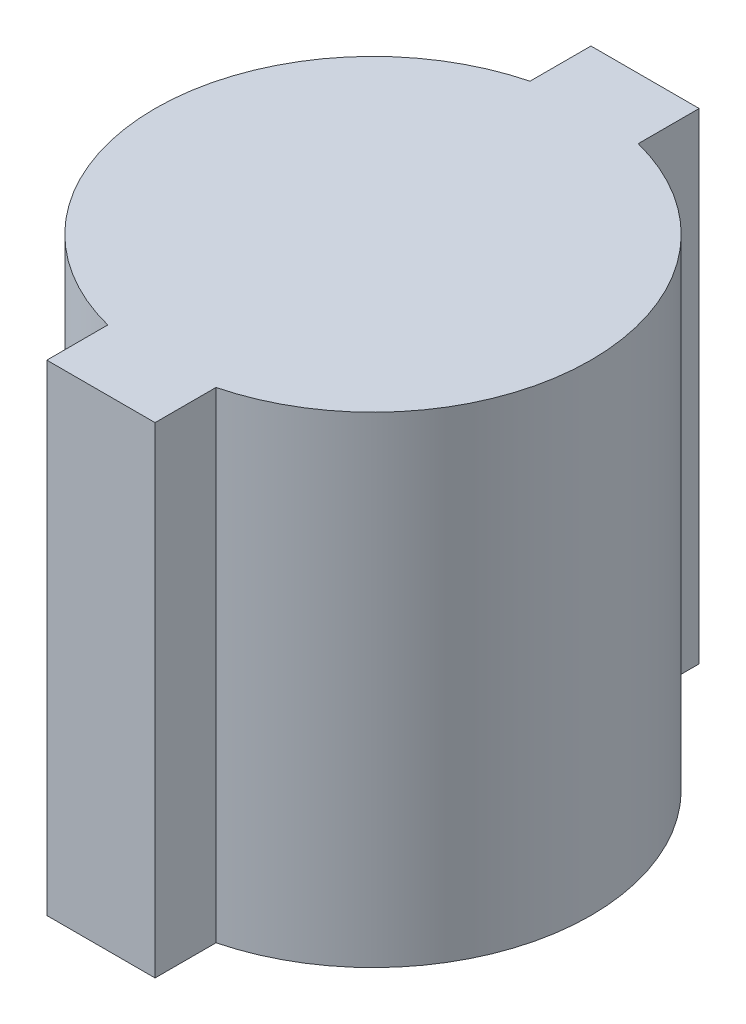
from build123d import *

# Parameters (mm, degrees)
BOSS_EXTRUDE1_DEPTH = 20.32


with BuildPart() as part:
    # Sketch1 → Boss-Extrude1 (new body)
    with BuildSketch(Plane(origin=(0, 0, 0), x_dir=(1, 0, 0), z_dir=(0, 1, 0))):
        with BuildLine():
            Line((-2.286, 11.4935), (-2.286, 8.919207378))
            ThreePointArc((-2.286, 8.919207378), (0, 9.2075), (2.286, 8.919207378))
            Line((2.286, 8.919207378), (2.286, 11.4935))
            Line((2.286, 11.4935), (-2.286, 11.4935))
        make_face()
        with BuildLine():
            Line((-2.286, 8.919207378), (-2.286, 6.9215))
            Line((-2.286, 6.9215), (2.286, 6.9215))
            Line((2.286, 6.9215), (2.286, 8.919207378))
            ThreePointArc((2.286, 8.919207378), (0, 9.2075), (-2.286, 8.919207378))
        make_face()
        with BuildLine():
            Line((2.286, 6.9215), (-2.286, 6.9215))
            Line((-2.286, 6.9215), (-2.286, 8.919207378))
            ThreePointArc((-2.286, 8.919207378), (-9.2075, 0), (-2.286, -8.919207378))
            Line((-2.286, -8.919207378), (-2.286, -6.9215))
            Line((-2.286, -6.9215), (2.286, -6.9215))
            Line((2.286, -6.9215), (2.286, -8.919207378))
            ThreePointArc((2.286, -8.919207378), (7.274146041, -5.644896423), (9.2075, 0))
            ThreePointArc((9.2075, 0), (7.274146041, 5.644896423), (2.286, 8.919207378))
            Line((2.286, 8.919207378), (2.286, 6.9215))
        make_face()
        with BuildLine():
            Line((-2.286, -6.9215), (-2.286, -8.919207378))
            ThreePointArc((-2.286, -8.919207378), (0, -9.2075), (2.286, -8.919207378))
            Line((2.286, -8.919207378), (2.286, -6.9215))
            Line((2.286, -6.9215), (-2.286, -6.9215))
        make_face()
        with BuildLine():
            ThreePointArc((2.286, -8.919207378), (0, -9.2075), (-2.286, -8.919207378))
            Line((-2.286, -8.919207378), (-2.286, -11.4935))
            Line((-2.286, -11.4935), (2.286, -11.4935))
            Line((2.286, -11.4935), (2.286, -8.919207378))
        make_face()
    extrude(amount=BOSS_EXTRUDE1_DEPTH)


solid = part.part
